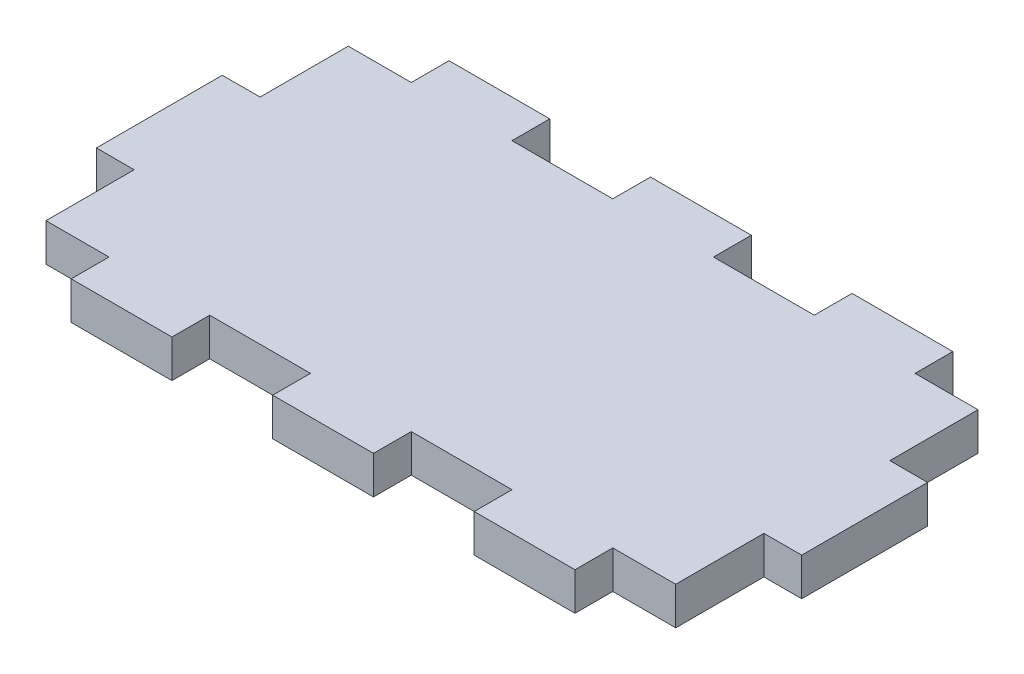
from build123d import *

# Parameters (mm, degrees)
AUFSATZ_LINEAR_AUSTRAGEN1_DEPTH = 3


with BuildPart() as part:
    # Skizze1 → Aufsatz-Linear austragen1 (new body)
    with BuildSketch(Plane(origin=(0, 0, 0), x_dir=(1, 0, 0), z_dir=(0, 1, 0))):
        Polygon((2.999994, 26.999946), (2.999994, 19.999706), (0, 19.999706), (0, 10.000742), (2.999994, 10.000742), (2.999994, 3.000248), (8.001, 3.000248), (8.001, 0), (16.000222, 0), (16.000222, 3.000248), (23.999952, 3.000248), (23.999952, 0), (32.000952, 0), (32.000952, 3.000248), (40.000428, 3.000248), (40.000428, 0), (48.001174, 0), (48.001174, 3.000248), (53.000656, 3.000248), (53.000656, 10.000742), (56.00065, 10.000742), (56.00065, 19.999706), (53.000656, 19.999706), (53.000656, 26.999946), (48.001174, 26.999946), (48.001174, 29.99994), (40.000428, 29.99994), (40.000428, 26.999946), (32.000952, 26.999946), (32.000952, 29.99994), (23.999952, 29.99994), (23.999952, 26.999946), (16.000222, 26.999946), (16.000222, 29.99994), (8.001, 29.99994), (8.001, 26.999946), align=None)
    extrude(amount=AUFSATZ_LINEAR_AUSTRAGEN1_DEPTH)


solid = part.part
